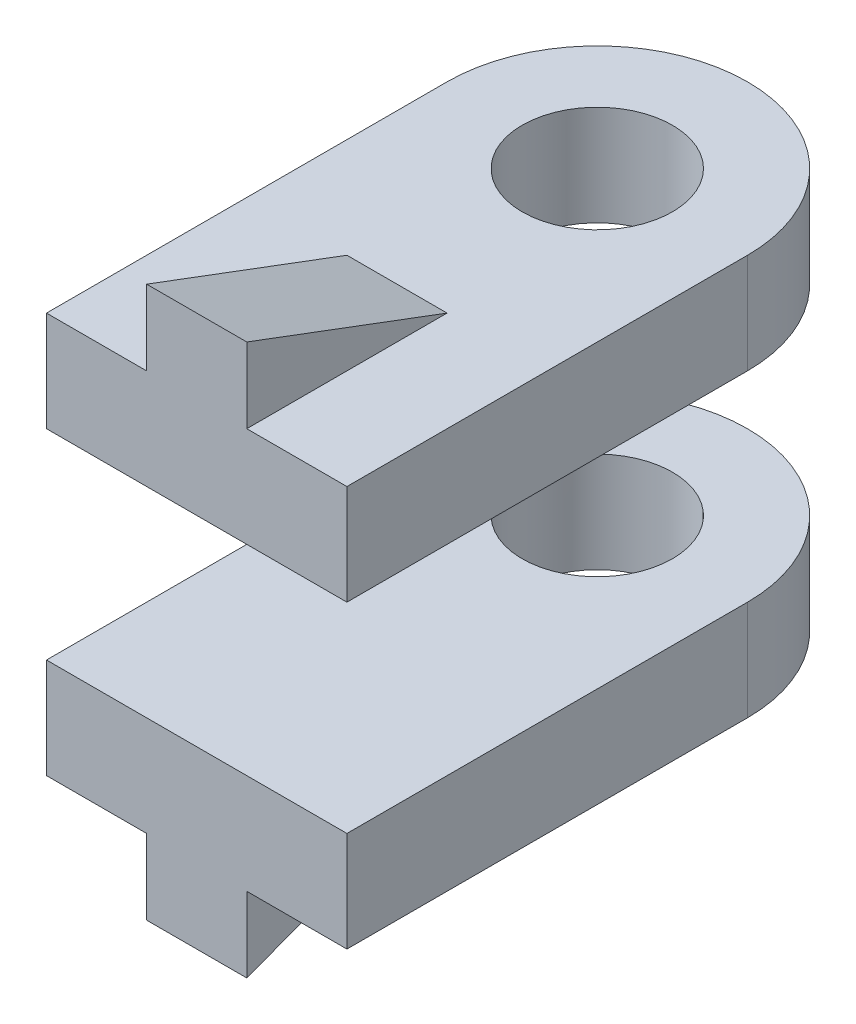
from build123d import *

# Parameters (mm, degrees)
SKETCH_1_R          = 15
EXTRUDE_2_DEPTH     = 40
SKETCH_2_W          = 60
SKETCH_2_H          = 40
CUT_EXTRUDE_1_DEPTH = 110
EXTRUDE_3_DEPTH     = 10


with BuildPart() as part:
    # 草图1 → 凸台-拉伸2 (new body, symmetric)
    with BuildSketch(Plane(origin=(0, 0, 0), x_dir=(1, 0, 0), z_dir=(0, 1, 0))):
        with BuildLine():
            Line((-30, 0), (-30, 80))
            ThreePointArc((-30, 80), (0, 110), (30, 80))
            Line((30, 80), (30, 0))
            Line((30, 0), (-30, 0))
        make_face()
        with Locations((0, 80)):
            Circle(SKETCH_1_R, mode=Mode.SUBTRACT)
    extrude(amount=EXTRUDE_2_DEPTH, both=True)

    # 草图2 → 切除-拉伸1 (cut)
    with BuildSketch(Plane.XY):
        Rectangle(SKETCH_2_W, SKETCH_2_H)
    extrude(amount=-CUT_EXTRUDE_1_DEPTH, mode=Mode.SUBTRACT)

    # 草图3 → 凸台-拉伸3 (add, symmetric)
    with BuildSketch(Plane(origin=(0, 0, 0), x_dir=(0, 0, -1), z_dir=(1, 0, 0))):
        Polygon((0, -55), (40, -40), (0, -40), align=None)
        Polygon((0, 55), (40, 40), (0, 40), align=None)
    extrude(amount=EXTRUDE_3_DEPTH, both=True)


solid = part.part
